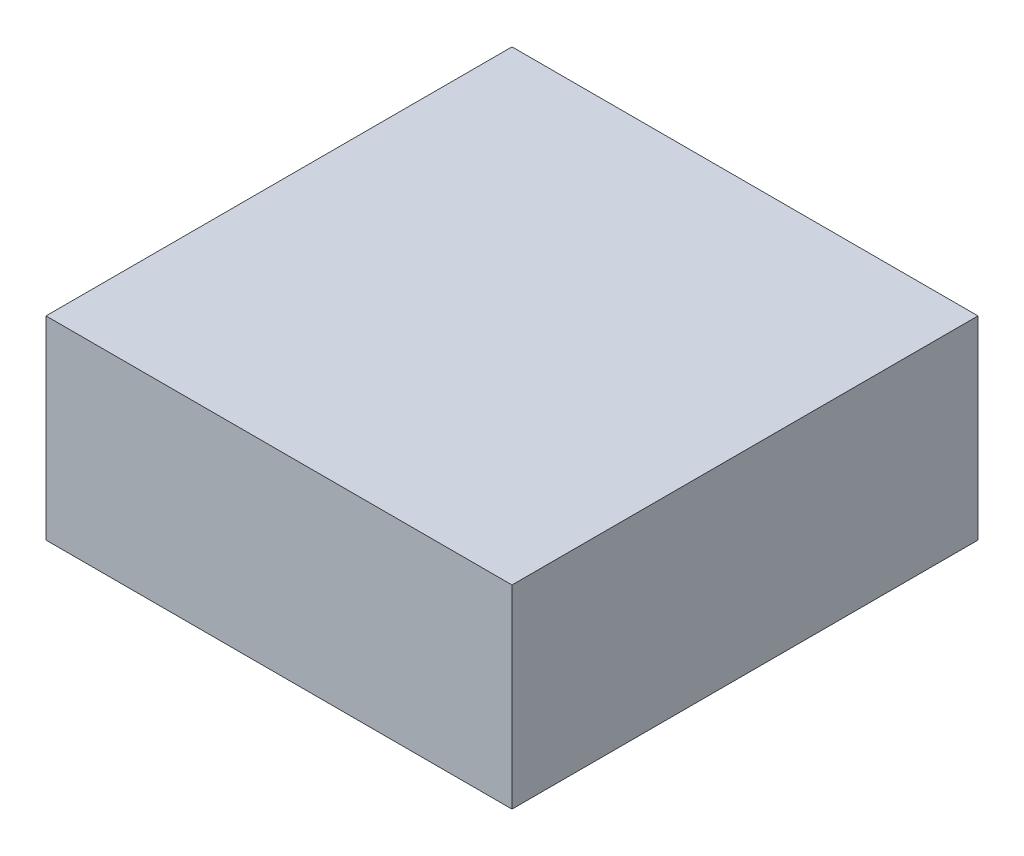
from build123d import *

# Parameters (mm, degrees)
SKETCH1_W           = 1200
SKETCH1_H           = 1200
BOSS_EXTRUDE1_DEPTH = 500


with BuildPart() as part:
    # Sketch1 → Boss-Extrude1 (new body)
    with BuildSketch(Plane(origin=(0, 0, 0), x_dir=(1, 0, 0), z_dir=(0, 1, 0))):
        Rectangle(SKETCH1_W, SKETCH1_H)
    extrude(amount=BOSS_EXTRUDE1_DEPTH)


solid = part.part
